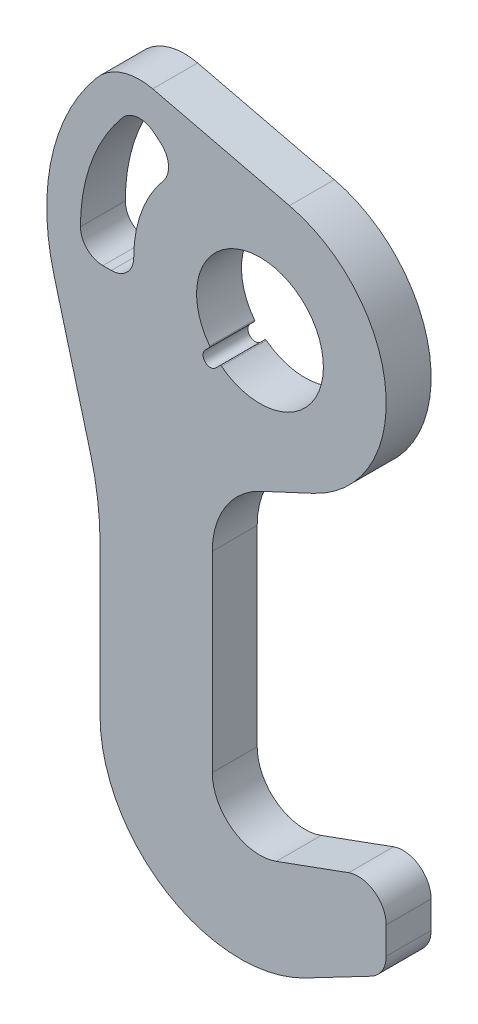
from build123d import *

# Parameters (mm, degrees)
BASE_EXTRUDE_DEPTH = 16


with BuildPart() as part:
    # Sketch1 → Base-Extrude (new body)
    with BuildSketch(Plane.XY):
        with BuildLine():
            Line((5.814342437, -160.974774553), (31.579798567, -151.59691545))
            ThreePointArc((31.579798567, -151.59691545), (40.735764364, -152.802321215), (45, -160.993841658))
            Line((45, -160.993841658), (45, -170.660453173))
            ThreePointArc((45, -170.660453173), (43.555274843, -175.838027157), (39.638545529, -179.519566863))
            Line((39.638545529, -179.519566863), (16.192727646, -191.79556845))
            ThreePointArc((16.192727646, -191.79556845), (-32.887869917, -190.276374217), (-57, -147.5))
            Line((-57, -147.5), (-57, -94.079804919))
            ThreePointArc((-57, -94.079804919), (-57.855513863, -81.027185697), (-60.407417371, -68.197900409))
            Line((-60.407417371, -68.197900409), (-73.410362798, -19.670247428))
            ThreePointArc((-73.410362798, -19.670247428), (-74.198496541, 16.449410659), (-58.219377677, 48.851858336))
            ThreePointArc((-58.219377677, 48.851858336), (-49.164213844, 54.989280966), (-38.234596516, 55.444707856))
            Line((-38.234596516, 55.444707856), (10.493757672, 43.759353856))
            ThreePointArc((10.493757672, 43.759353856), (44.773001659, 4.514235528), (19.017821778, -40.783850417))
            Line((19.017821778, -40.783850417), (0.321452148, -49.502110755))
            ThreePointArc((0.321452148, -49.502110755), (-12.301743374, -60.572356116), (-17, -76.691344366))
            Line((-17, -76.691344366), (-17, -145))
            ThreePointArc((-17, -145), (-9.750799418, -158.925584753), (5.814342437, -160.974774553))
        make_face()
        with BuildLine():
            Line((-15.821514229, -19.53382483), (-14.266024685, -17.978335287))
            ThreePointArc((-14.266024685, -17.978335287), (-14.009543632, -17.862047616), (-13.739996199, -17.943592295))
            ThreePointArc((-13.739996199, -17.943592295), (15.980613255, 15.980613255), (-17.943592295, -13.739996199))
            ThreePointArc((-17.943592295, -13.739996199), (-17.862047616, -14.009543632), (-17.978335287, -14.266024685))
            Line((-17.978335287, -14.266024685), (-19.53382483, -15.821514229))
            ThreePointArc((-19.53382483, -15.821514229), (-19.53382483, -19.53382483), (-15.821514229, -19.53382483))
        make_face(mode=Mode.SUBTRACT)
        with BuildLine():
            Line((-53, -8), (-56, -8))
            ThreePointArc((-56, -8), (-61.656854249, -5.656854249), (-64, 0))
            ThreePointArc((-64, 0), (-60.14032773, 21.889289173), (-49.02684436, 41.13840702))
            ThreePointArc((-49.02684436, 41.13840702), (-43.595734757, 43.965663727), (-37.756187937, 42.124461687))
            Line((-37.756187937, 42.124461687), (-35.458054608, 40.196098858))
            ThreePointArc((-35.458054608, 40.196098858), (-32.630797901, 34.764989255), (-34.47199994, 28.925442436))
            ThreePointArc((-34.47199994, 28.925442436), (-42.286167935, 15.39090645), (-45, 0))
            ThreePointArc((-45, 0), (-47.343145751, -5.656854249), (-53, -8))
        make_face(mode=Mode.SUBTRACT)
    extrude(amount=BASE_EXTRUDE_DEPTH)


solid = part.part
